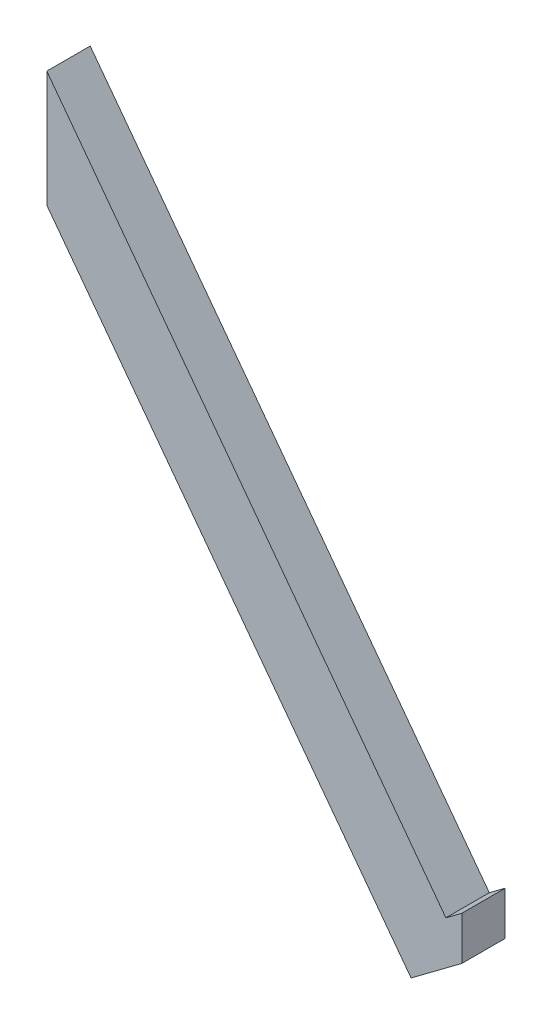
from build123d import *

# Parameters (mm, degrees)
SALIENTE_EXTRUIR1_DEPTH = 5


with BuildPart() as part:
    # Croquis1 → Saliente-Extruir1 (new body)
    with BuildSketch(Plane.XY):
        Polygon((-48.451057668, 38.396793067), (-2.523567422, -23.017874122), (-0.693903445, -21.649603669), (-0.693903445, -26.656094086), (-6.529092756, -31.019800875), (-48.451057668, 25.038640576), align=None)
    extrude(amount=SALIENTE_EXTRUIR1_DEPTH)


solid = part.part
